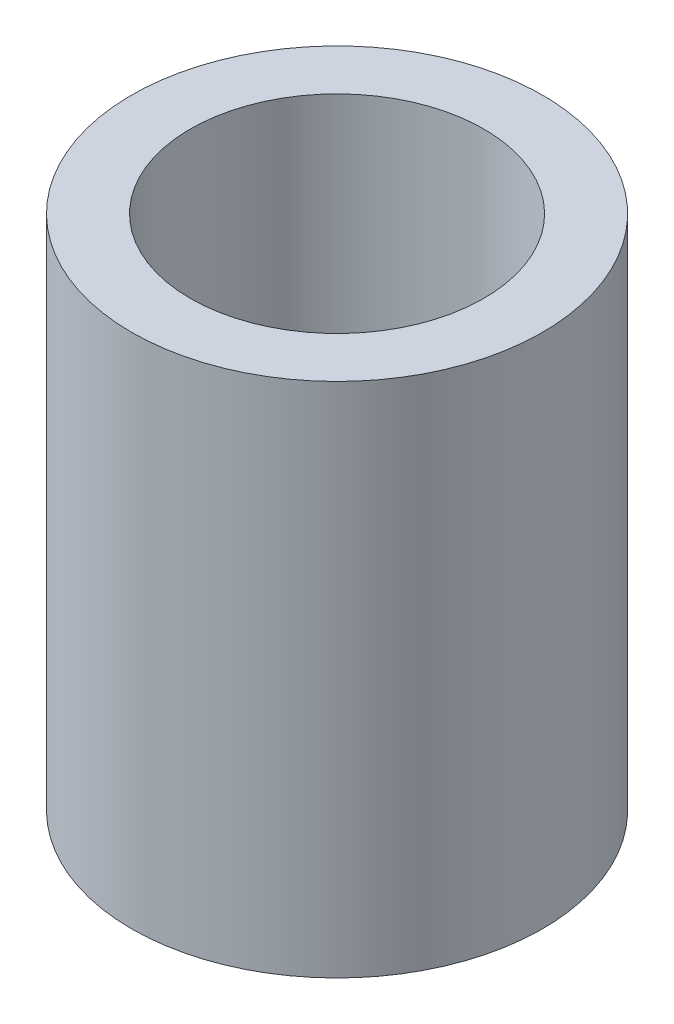
from build123d import *

# Parameters (mm, degrees)
SKETCH1_R           = 5.55625
SKETCH1_R_2         = 3.96875
BOSS_EXTRUDE1_DEPTH = 13.97


with BuildPart() as part:
    # Sketch1 → Boss-Extrude1 (new body)
    with BuildSketch(Plane(origin=(0, 0, 0), x_dir=(1, 0, 0), z_dir=(0, 1, 0))):
        Circle(SKETCH1_R)
        Circle(SKETCH1_R_2, mode=Mode.SUBTRACT)
    extrude(amount=-BOSS_EXTRUDE1_DEPTH)


solid = part.part
